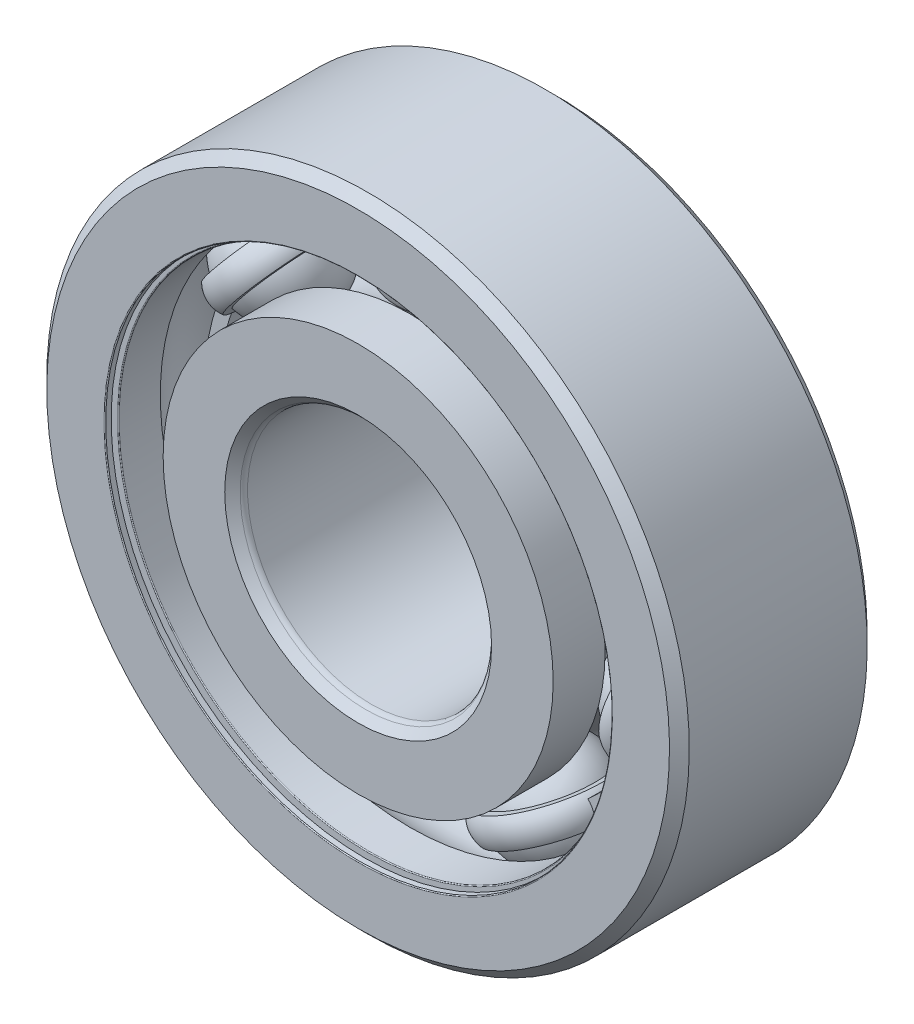
from build123d import *

# Parameters (mm, degrees)
BOSS_EXTRUDE1_DEPTH = 0.666666667
CIRPATTERN1_COUNT   = 7
CIRPATTERN2_COUNT   = 7
FILLET1_R           = 0.036
FILLET2_R           = 0.3


with BuildPart() as part:
    # Sketch3 → Revolve1 (revolve)
    with BuildSketch(Plane(origin=(0, 0, 0), x_dir=(0, 0, -1), z_dir=(1, 0, 0))):
        with BuildLine():
            Line((3.6, 13), (4, 12.6))
            Line((4, 12.6), (4, 10.107692308))
            Line((4, 10.107692308), (1.9, 10.107692308))
            ThreePointArc((1.9, 10.107692308), (0, 11.19931404), (-1.9, 10.107692308))
            Line((-1.9, 10.107692308), (-4, 10.107692308))
            Line((-4, 10.107692308), (-4, 12.6))
            Line((-4, 12.6), (-3.6, 13))
            Line((-3.6, 13), (3.6, 13))
        make_face()
    revolve(axis=Axis((0, 0, 4), (0, 0, -1)))

    # Sketch8 → Cut-Revolve1 (revolve, cut)
    with BuildSketch(Plane(origin=(0, 0, 0), x_dir=(0, 0, -1), z_dir=(1, 0, 0))):
        Polygon((-3.744, 10.107692308), (-3.6, 10.107692308), (-3.6, 11.071794872), (-3.744, 11.071794872), (-3.744, 10.251692308), (-4, 10.251692308), (-4, 10.107692308), align=None)
        Polygon((3.6, 10.107692308), (3.744, 10.107692308), (4, 10.107692308), (4, 10.251692308), (3.744, 10.251692308), (3.744, 11.071794872), (3.6, 11.071794872), align=None)
    revolve(axis=Axis((0, 0, 4), (0, 0, -1)), mode=Mode.SUBTRACT)

    # Fillet1
    fillet1_edges = [part.edges().sort_by_distance(p)[0] for p in [
        (0, -10.107692308, -3.6),
        (0, -10.251692308, -4),
        (0, -10.107692308, 3.6),
        (0, -10.251692308, 4),
    ]]
    fillet(fillet1_edges, radius=FILLET1_R)


with BuildPart() as body_2:
    # Sketch4 → Revolve2 (revolve)
    with BuildSketch(Plane(origin=(0, 0, 0), x_dir=(0, 0, -1), z_dir=(1, 0, 0))):
        with BuildLine():
            Line((-3.6, 5), (-4, 5.4))
            Line((-4, 5.4), (-4, 7.892307692))
            Line((-4, 7.892307692), (-1.9, 7.892307692))
            ThreePointArc((-1.9, 7.892307692), (0, 6.80068596), (1.9, 7.892307692))
            Line((1.9, 7.892307692), (4, 7.892307692))
            Line((4, 7.892307692), (4, 5.4))
            Line((4, 5.4), (3.6, 5))
            Line((3.6, 5), (-3.6, 5))
        make_face()
    revolve(axis=Axis((0, 0, 4), (0, 0, -1)))

    # Fillet2
    fillet2_edges = [body_2.edges().sort_by_distance(p)[0] for p in [
        (0, -5, -3.6),
        (0, -5, 3.6),
    ]]
    fillet(fillet2_edges, radius=FILLET2_R)


with BuildPart() as body_3:
    # Sketch5 → Revolve3 (revolve)
    with BuildSketch(Plane(origin=(0, 0, 0), x_dir=(0, 0, -1), z_dir=(1, 0, 0))):
        with BuildLine():
            Line((-2.19931404, 9), (2.19931404, 9))
            ThreePointArc((2.19931404, 9), (0, 11.19931404), (-2.19931404, 9))
        make_face()
    revolve(axis=Axis((0, 9, 2.19931404), (0, 0, -1)))


with BuildPart() as body_4:
    # Sketch6 → Revolve4 (revolve)
    with BuildSketch(Plane(origin=(0, 0, 0), x_dir=(0, 0, -1), z_dir=(1, 0, 0))):
        with BuildLine():
            Line((-2.128435267, 9.553846154), (-2.440362723, 9.553846154))
            ThreePointArc((-2.440362723, 9.553846154), (-2.59632645, 9), (-2.440362723, 8.446153846))
            Line((-2.440362723, 8.446153846), (-2.128435267, 8.446153846))
            ThreePointArc((-2.128435267, 8.446153846), (-2.19931404, 9), (-2.128435267, 9.553846154))
        make_face()
    revolve4 = revolve(axis=Axis((0, 13, 0), (0, -1, 0)))

    # Sketch7 → Boss-Extrude1 (add, symmetric)
    with BuildSketch(Plane.XY):
        with BuildLine():
            Line((7.036483342, 5.611408217), (7.469497702, 5.956725645))
            ThreePointArc((7.469497702, 5.956725645), (4.145258492, 8.607717953), (0, 9.553846154))
            Line((0, 9.553846154), (0, 9))
            ThreePointArc((0, 9), (3.904953652, 8.108719811), (7.036483342, 5.611408217))
        make_face()
    boss_extrude1 = extrude(amount=BOSS_EXTRUDE1_DEPTH, both=True)

    # CirPattern2: Revolve4, Boss-Extrude1 ×7 about axis
    cirpattern2_axis = Axis((0, 0, 4), (0, 0, -1))
    add([revolve4.rotate(cirpattern2_axis, i * 360 / CIRPATTERN2_COUNT) for i in range(1, CIRPATTERN2_COUNT)])
    add([boss_extrude1.rotate(cirpattern2_axis, i * 360 / CIRPATTERN2_COUNT) for i in range(1, CIRPATTERN2_COUNT)])


with BuildPart() as cirpattern1_1:
    # CirPattern1: pattern copy
    add(body_3.part.rotate(Axis((0, 0, 4), (0, 0, -1)), 1 * 360 / CIRPATTERN1_COUNT))


with BuildPart() as cirpattern1_2:
    # CirPattern1: pattern copy
    add(body_3.part.rotate(Axis((0, 0, 4), (0, 0, -1)), 2 * 360 / CIRPATTERN1_COUNT))


with BuildPart() as cirpattern1_3:
    # CirPattern1: pattern copy
    add(body_3.part.rotate(Axis((0, 0, 4), (0, 0, -1)), 3 * 360 / CIRPATTERN1_COUNT))


with BuildPart() as cirpattern1_4:
    # CirPattern1: pattern copy
    add(body_3.part.rotate(Axis((0, 0, 4), (0, 0, -1)), 4 * 360 / CIRPATTERN1_COUNT))


with BuildPart() as cirpattern1_5:
    # CirPattern1: pattern copy
    add(body_3.part.rotate(Axis((0, 0, 4), (0, 0, -1)), 5 * 360 / CIRPATTERN1_COUNT))


with BuildPart() as cirpattern1_6:
    # CirPattern1: pattern copy
    add(body_3.part.rotate(Axis((0, 0, 4), (0, 0, -1)), 6 * 360 / CIRPATTERN1_COUNT))


solid = Compound([part.part, body_2.part, body_3.part, body_4.part, cirpattern1_1.part, cirpattern1_2.part, cirpattern1_3.part, cirpattern1_4.part, cirpattern1_5.part, cirpattern1_6.part])
